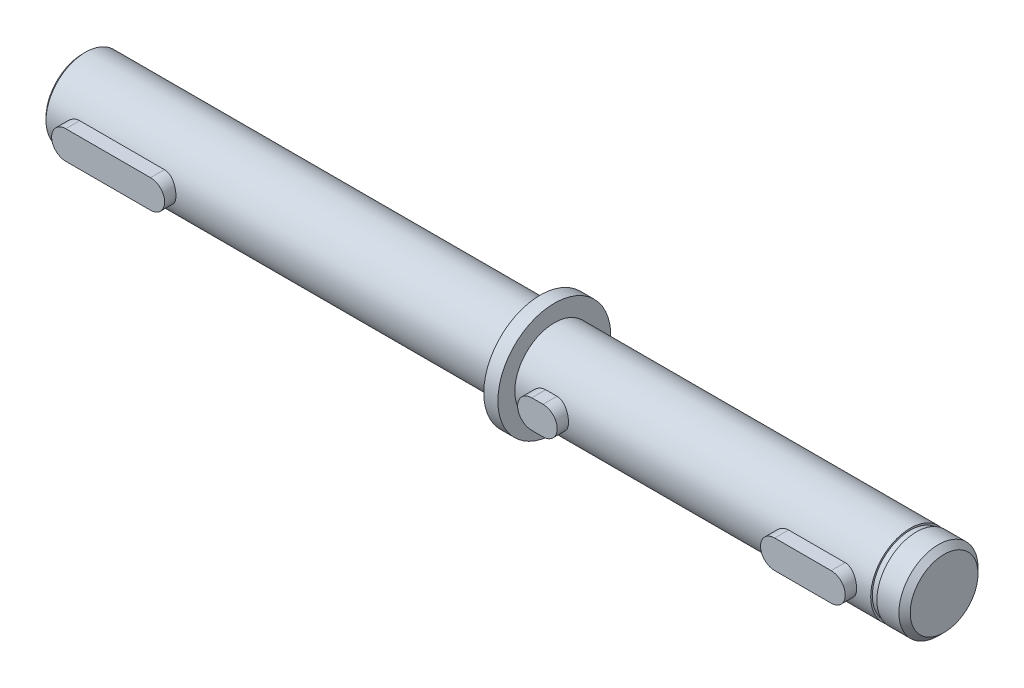
from build123d import *

# Parameters (mm, degrees)
EXTRUDE_1_DEPTH        = 9
SKETCH_3_R             = 15
CUT_EXTRUDE_1_DEPTH    = 26.5
HOLE_WIZARD_M6_1_D     = 5
HOLE_WIZARD_M6_1_DEPTH = 17
HOLE_WIZARD_M6_1_TIP   = 1.502151548
CHAMFER_1_SIZE         = 1
SKETCH_6_W             = 1.1
SKETCH_6_H             = 0.3


with BuildPart() as part:
    # 草图1 → 旋转1 (revolve)
    with BuildSketch(Plane.XY, mode=Mode.PRIVATE) as revolve_1_sk:
        Polygon((-89.5, 0), (89.5, 0), (89.5, 6), (88.5, 7), (-6, 7), (-6, 10), (-8.5, 10), (-8.5, 7), (-89, 7), (-89.5, 6.5), align=None)
    revolve(revolve_1_sk.sketch.rotate(Axis((-89.5, 0, 0), (1, 0, 0)), 90), axis=Axis((-89.5, 0, 0), (1, 0, 0)))

    # 草图2 → 凸台-拉伸1 (add)
    with BuildSketch(Plane.XY):
        with BuildLine():
            Line((68.5, -2.5), (83.5, -2.5))
            ThreePointArc((83.5, -2.5), (86, 0), (83.5, 2.5))
            Line((83.5, 2.5), (68.5, 2.5))
            ThreePointArc((68.5, 2.5), (66, 0), (68.5, -2.5))
        make_face()
        with BuildLine():
            ThreePointArc((-83.5, 2.5), (-86, 0), (-83.5, -2.5))
            Line((-83.5, -2.5), (-68.5, -2.5))
            ThreePointArc((-68.5, -2.5), (-66, 0), (-68.5, 2.5))
            Line((-68.5, 2.5), (-83.5, 2.5))
        make_face()
        with BuildLine():
            Line((1, 2.5), (-1, 2.5))
            ThreePointArc((-1, 2.5), (-3.5, 0), (-1, -2.5))
            Line((-1, -2.5), (1, -2.5))
            ThreePointArc((1, -2.5), (3.5, 0), (1, 2.5))
        make_face()
        with BuildLine():
            Line((52, 2.5), (42, 2.5))
            ThreePointArc((42, 2.5), (39.5, 0), (42, -2.5))
            Line((42, -2.5), (52, -2.5))
            ThreePointArc((52, -2.5), (54.5, 0), (52, 2.5))
        make_face()
    extrude(amount=EXTRUDE_1_DEPTH)

    # 草图3 → 切除-拉伸1 (cut)
    with BuildSketch(Plane(origin=(89.5, 0, 0), x_dir=(0, 0, -1), z_dir=(1, 0, 0))):
        Circle(SKETCH_3_R)
    extrude(amount=-CUT_EXTRUDE_1_DEPTH, mode=Mode.SUBTRACT)

    # M6 螺纹孔1
    with Locations(Plane.ZY.offset(89.5)):
        with Locations((0, 0)):
            Hole(HOLE_WIZARD_M6_1_D / 2, depth=HOLE_WIZARD_M6_1_DEPTH)
            with Locations((0, 0, -(HOLE_WIZARD_M6_1_DEPTH + HOLE_WIZARD_M6_1_TIP / 2))):  # 118° drill point
                Cone(0, HOLE_WIZARD_M6_1_D / 2, HOLE_WIZARD_M6_1_TIP, mode=Mode.SUBTRACT)

    # 倒角1
    chamfer_1_edges = [part.edges().sort_by_distance(p)[0] for p in [
        (63, 0, -7),
    ]]
    chamfer(chamfer_1_edges, length=CHAMFER_1_SIZE)

    # 草图6 → 切除-旋转1 (revolve, cut)
    with BuildSketch(Plane.XY, mode=Mode.PRIVATE) as cut_revolve_1_sk:
        with Locations((57.55, -6.85)):
            Rectangle(SKETCH_6_W, SKETCH_6_H)
    revolve(cut_revolve_1_sk.sketch.rotate(Axis((0, 0, 0), (1, 0, 0)), 270), axis=Axis((0, 0, 0), (1, 0, 0)), mode=Mode.SUBTRACT)


solid = part.part
